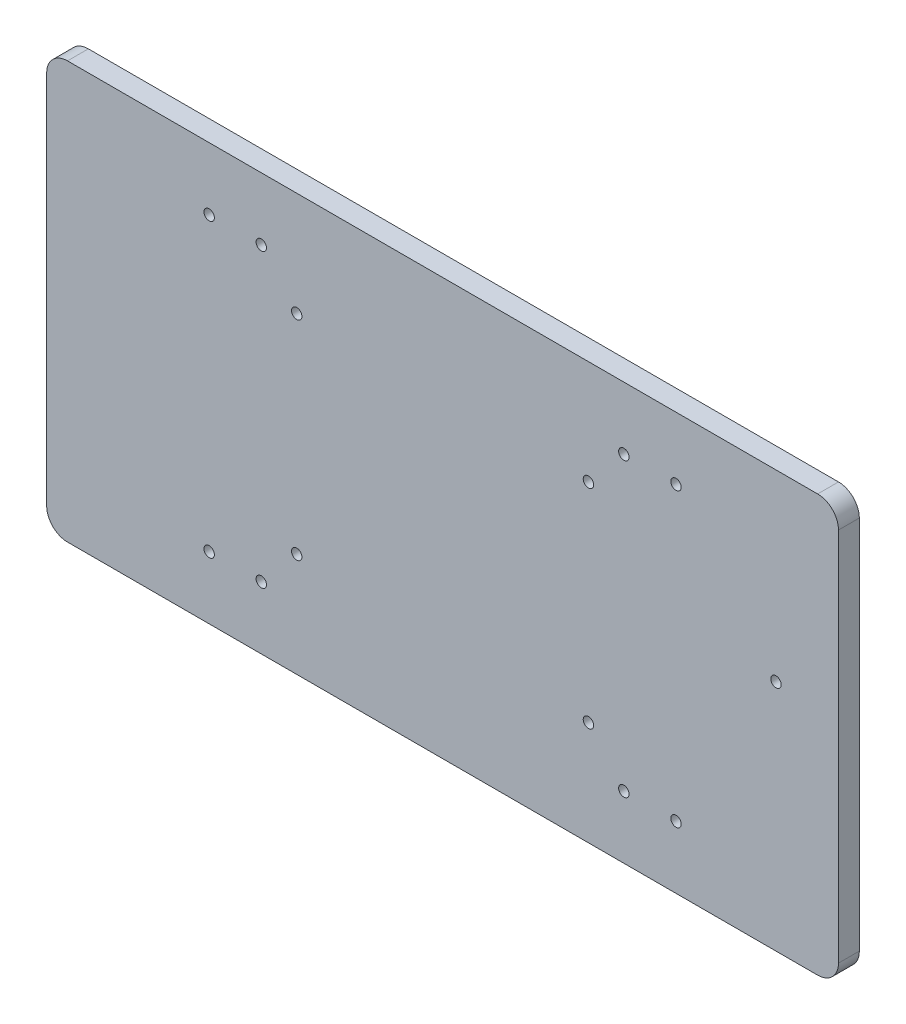
from build123d import *

# Parameters (mm, degrees)
SKETCH1_W           = 190
SKETCH1_H           = 100
SKETCH1_R           = 1.25
BOSS_EXTRUDE2_DEPTH = 5
FILLET1_R           = 5


with BuildPart() as part:
    # Sketch1 → Boss-Extrude2 (new body)
    with BuildSketch(Plane.XY):
        Rectangle(SKETCH1_W, SKETCH1_H)
        with Locations((-35, 25)):
            Circle(SKETCH1_R, mode=Mode.SUBTRACT)
        with Locations((35, -25)):
            Circle(SKETCH1_R, mode=Mode.SUBTRACT)
        with Locations((-35, -25)):
            Circle(SKETCH1_R, mode=Mode.SUBTRACT)
        with Locations((35, 25)):
            Circle(SKETCH1_R, mode=Mode.SUBTRACT)
        with Locations((80, 5.969945355)):
            Circle(SKETCH1_R, mode=Mode.SUBTRACT)
        with Locations((-43.5, -35)):
            Circle(SKETCH1_R, mode=Mode.SUBTRACT)
        with Locations((-56.009274653, -35)):
            Circle(SKETCH1_R, mode=Mode.SUBTRACT)
        with Locations((-56.009274653, 35)):
            Circle(SKETCH1_R, mode=Mode.SUBTRACT)
        with Locations((-43.5, 35)):
            Circle(SKETCH1_R, mode=Mode.SUBTRACT)
        with Locations((43.5, -35)):
            Circle(SKETCH1_R, mode=Mode.SUBTRACT)
        with Locations((56.009274653, -35)):
            Circle(SKETCH1_R, mode=Mode.SUBTRACT)
        with Locations((43.5, 35)):
            Circle(SKETCH1_R, mode=Mode.SUBTRACT)
        with Locations((56.009274653, 35)):
            Circle(SKETCH1_R, mode=Mode.SUBTRACT)
    extrude(amount=BOSS_EXTRUDE2_DEPTH)

    # Fillet1
    fillet1_edges = [part.edges().sort_by_distance(p)[0] for p in [
        (95, 50, 2.5),
        (95, -50, 2.5),
        (-95, -50, 2.5),
        (-95, 50, 2.5),
    ]]
    fillet(fillet1_edges, radius=FILLET1_R)


solid = part.part
